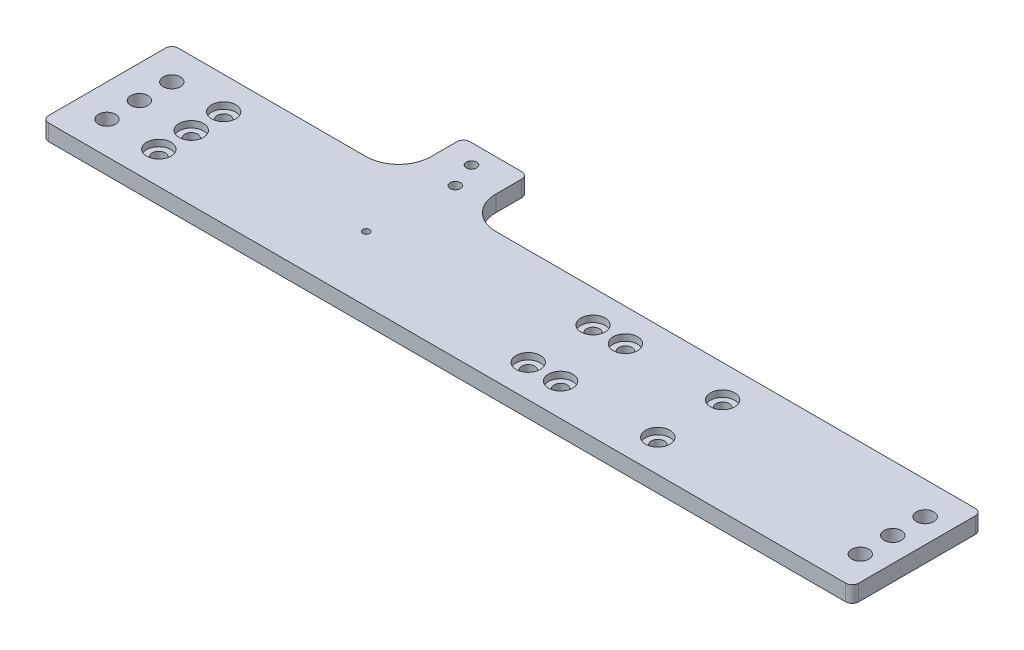
from build123d import *

# Parameters (mm, degrees)
SKETCH1_W                                       = 317.5
SKETCH1_H                                       = 50.8
BOSS_EXTRUDE1_DEPTH                             = 6.35
CBORE_FOR_10_SOCKET_HEAD_CAP_SCREW1_D           = 5.1054
CBORE_FOR_10_SOCKET_HEAD_CAP_SCREW1_CBORE_D     = 9.525
CBORE_FOR_10_SOCKET_HEAD_CAP_SCREW1_CBORE_DEPTH = 2.54
F_1_4_CLEARANCE_HOLE2_D                         = 6.7564
F_6_32_TAPPED_HOLE1_D                           = 2.7051
SKETCH12_W                                      = 25.4
SKETCH12_H                                      = 25.4
BOSS_EXTRUDE3_DEPTH                             = 6.35
F_10_32_TAPPED_HOLE1_D                          = 4.0386
FILLET1_R                                       = 12.7
FILLET2_R                                       = 2.54


with BuildPart() as part:
    # Sketch1 → Boss-Extrude1 (new body)
    with BuildSketch(Plane(origin=(0, 0, 0), x_dir=(1, 0, 0), z_dir=(0, 1, 0))):
        Rectangle(SKETCH1_W, SKETCH1_H)
    extrude(amount=BOSS_EXTRUDE1_DEPTH)

    # CBORE for #10 Socket Head Cap Screw1 (through all)
    with Locations(Plane(origin=(0, 6.35, 0), x_dir=(1, 0, 0), z_dir=(0, 1, 0))):
        with Locations((31.75, -12.7), (19.05, 12.7), (69.85, 12.7), (19.05, -12.7), (69.85, -12.7), (-125.73, 12.7), (-125.73, 0), (-125.73, -12.7), (31.75, 12.7)):
            CounterBoreHole(CBORE_FOR_10_SOCKET_HEAD_CAP_SCREW1_D / 2, CBORE_FOR_10_SOCKET_HEAD_CAP_SCREW1_CBORE_D / 2, CBORE_FOR_10_SOCKET_HEAD_CAP_SCREW1_CBORE_DEPTH)

    # 1/4 Clearance Hole2 (through all)
    with Locations(Plane.XZ):
        with Locations((-146.05, 12.7), (-146.05, 0), (-146.05, -12.7), (149.225, 12.7), (149.225, 0), (149.225, -12.7)):
            Hole(F_1_4_CLEARANCE_HOLE2_D / 2)

    # #6-32 Tapped Hole1 (through all)
    with Locations(Plane(origin=(0, 0, 0), x_dir=(-1, 0, 0), z_dir=(0, -1, 0))):
        with Locations((57.15, 0)):
            Hole(F_6_32_TAPPED_HOLE1_D / 2)

    # Sketch12 → Boss-Extrude3 (add)
    with BuildSketch(Plane(origin=(0, 6.35, 0), x_dir=(1, 0, 0), z_dir=(0, 1, 0))):
        with Locations((-57.15, 38.1)):
            Rectangle(SKETCH12_W, SKETCH12_H)
    extrude(amount=-BOSS_EXTRUDE3_DEPTH)

    # #10-32 Tapped Hole1 (through all)
    with Locations(Plane(origin=(0, 0, 0), x_dir=(-1, 0, 0), z_dir=(0, -1, 0))):
        with Locations((59.055, 43.18), (55.245, 33.02)):
            Hole(F_10_32_TAPPED_HOLE1_D / 2)

    # Fillet1
    fillet1_edges = [part.edges().sort_by_distance(p)[0] for p in [
        (-69.85, 3.175, -25.4),
        (-44.45, 3.175, -25.4),
    ]]
    fillet(fillet1_edges, radius=FILLET1_R)

    # Fillet2
    fillet2_edges = [part.edges().sort_by_distance(p)[0] for p in [
        (-44.45, 3.175, -50.8),
        (-69.85, 3.175, -50.8),
        (158.75, 3.175, 25.4),
        (-158.75, 3.175, 25.4),
        (-158.75, 3.175, -25.4),
        (158.75, 3.175, -25.4),
    ]]
    fillet(fillet2_edges, radius=FILLET2_R)


solid = part.part
